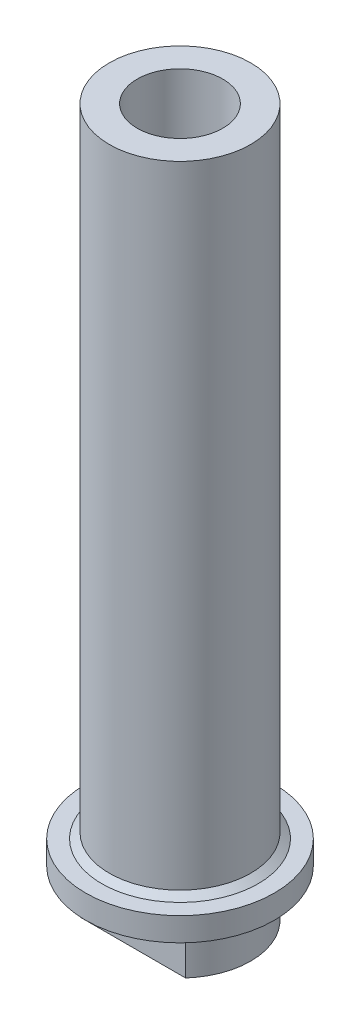
from build123d import *

# Parameters (mm, degrees)
SKETCH1_R                       = 9.525
SKETCH1_R_2                     = 3.175
BOSS_EXTRUDE1_DEPTH             = 95.25
SKETCH3_R                       = 12.7
SKETCH3_R_2                     = 9.525
BOSS_EXTRUDE2_DEPTH             = 3.175
SKETCH4_R                       = 6.35
BOSS_EXTRUDE3_DEPTH             = 19.05
TAP_DRILL_FOR_1_2_20_TAP1_D     = 11.50874
TAP_DRILL_FOR_1_2_20_TAP1_DEPTH = 19.05
CHAMFER1_SIZE                   = 1
CHAMFER1_SIZE2                  = 0.726542528
SKETCH8_W                       = 16.189039501
SKETCH8_H                       = 7.642767638
SKETCH8_H_2                     = 8.514884137
CUT_EXTRUDE1_DEPTH              = 6.35


with BuildPart() as part:
    # Sketch1 → Boss-Extrude1 (new body)
    with BuildSketch(Plane(origin=(0, 0, 0), x_dir=(1, 0, 0), z_dir=(0, 1, 0))):
        Circle(SKETCH1_R)
        Circle(SKETCH1_R_2, mode=Mode.SUBTRACT)
    extrude(amount=BOSS_EXTRUDE1_DEPTH)

    # Sketch3 → Boss-Extrude2 (add)
    with BuildSketch(Plane(origin=(0, 6.35, 0), x_dir=(-1, 0, 0), z_dir=(0, -1, 0))):
        Circle(SKETCH3_R)
        Circle(SKETCH3_R_2, mode=Mode.SUBTRACT)
    extrude(amount=-BOSS_EXTRUDE2_DEPTH)

    # Sketch4 → Boss-Extrude3 (add)
    with BuildSketch(Plane(origin=(0, 95.25, 0), x_dir=(1, 0, 0), z_dir=(0, 1, 0))):
        Circle(SKETCH4_R)
    extrude(amount=-BOSS_EXTRUDE3_DEPTH)

    # Tap Drill for 1/2-20 Tap1
    with Locations(Plane(origin=(0, 95.25, 0), x_dir=(1, 0, 0), z_dir=(0, 1, 0))):
        with Locations((0, 0)):
            Hole(TAP_DRILL_FOR_1_2_20_TAP1_D / 2, depth=TAP_DRILL_FOR_1_2_20_TAP1_DEPTH)

    # Chamfer1
    chamfer1_edges = [part.edges().sort_by_distance(p)[0] for p in [
        (-9.525, 9.525, 0),
    ]]
    chamfer1_side = [part.faces().sort_by_distance(p)[0] for p in [
        (12.340789755, 9.525, 0),
    ]]
    chamfer(chamfer1_edges, length=CHAMFER1_SIZE, length2=CHAMFER1_SIZE2, reference=chamfer1_side[0])

    # Sketch8 → Cut-Extrude1 (cut)
    with BuildSketch(Plane.XZ):
        with Locations((0.474519751, 10.171383819)):
            Rectangle(SKETCH8_W, SKETCH8_H)
        with Locations((0.474519751, -10.607442069)):
            Rectangle(SKETCH8_W, SKETCH8_H_2)
    extrude(amount=-CUT_EXTRUDE1_DEPTH, mode=Mode.SUBTRACT)


solid = part.part
